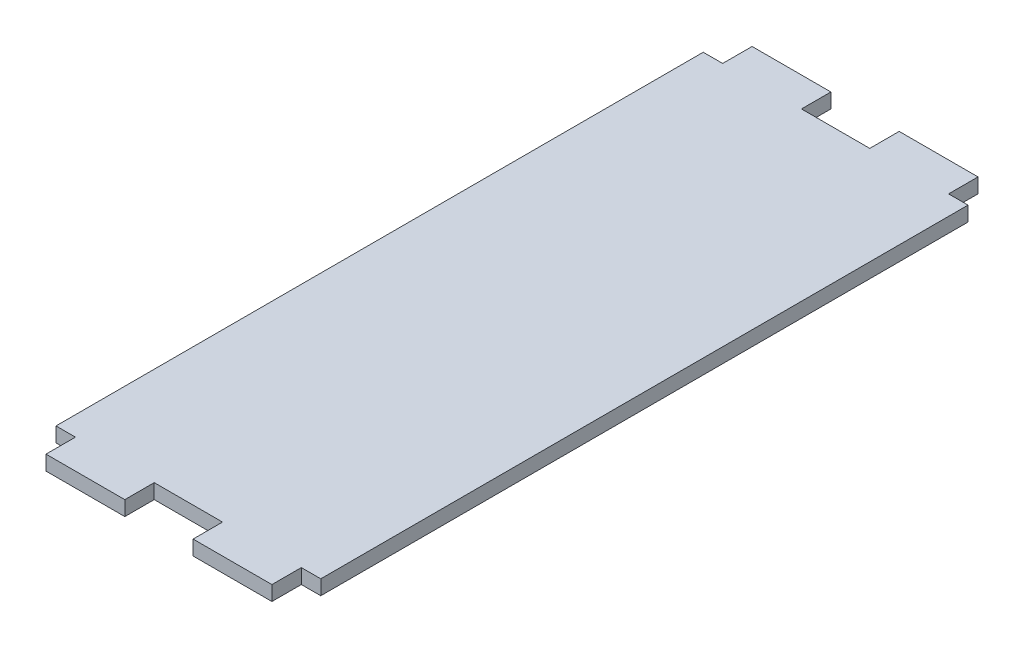
from build123d import *

# Parameters (mm, degrees)
SKETCH1_W           = 57.15
SKETCH1_H           = 152.4
BOSS_EXTRUDE1_DEPTH = 3.175
SKETCH2_W           = 4.195
SKETCH2_H           = 6.35
SKETCH2_W_2         = 7.37
CUT_EXTRUDE1_DEPTH  = 4.175


with BuildPart() as part:
    # Sketch1 → Boss-Extrude1 (new body)
    with BuildSketch(Plane(origin=(0, 0, 0), x_dir=(1, 0, 0), z_dir=(0, 1, 0))):
        Rectangle(SKETCH1_W, SKETCH1_H)
    extrude(amount=BOSS_EXTRUDE1_DEPTH)

    # Sketch2 → Cut-Extrude1 (cut, through all)
    with BuildSketch(Plane(origin=(0, 3.175, 0), x_dir=(1, 0, 0), z_dir=(0, 1, 0))):
        with Locations((-26.4775, -73.025)):
            Rectangle(SKETCH2_W, SKETCH2_H)
        with Locations((-3.685, -73.025)):
            Rectangle(SKETCH2_W_2, SKETCH2_H)
        with Locations((3.685, -73.025)):
            Rectangle(SKETCH2_W_2, SKETCH2_H)
        with Locations((26.4775, -73.025)):
            Rectangle(SKETCH2_W, SKETCH2_H)
    cut_extrude1 = extrude(amount=-CUT_EXTRUDE1_DEPTH, mode=Mode.SUBTRACT)

    # Mirror1: Cut-Extrude1 across plane
    add(cut_extrude1.mirror(Plane.XY), mode=Mode.SUBTRACT)


solid = part.part
